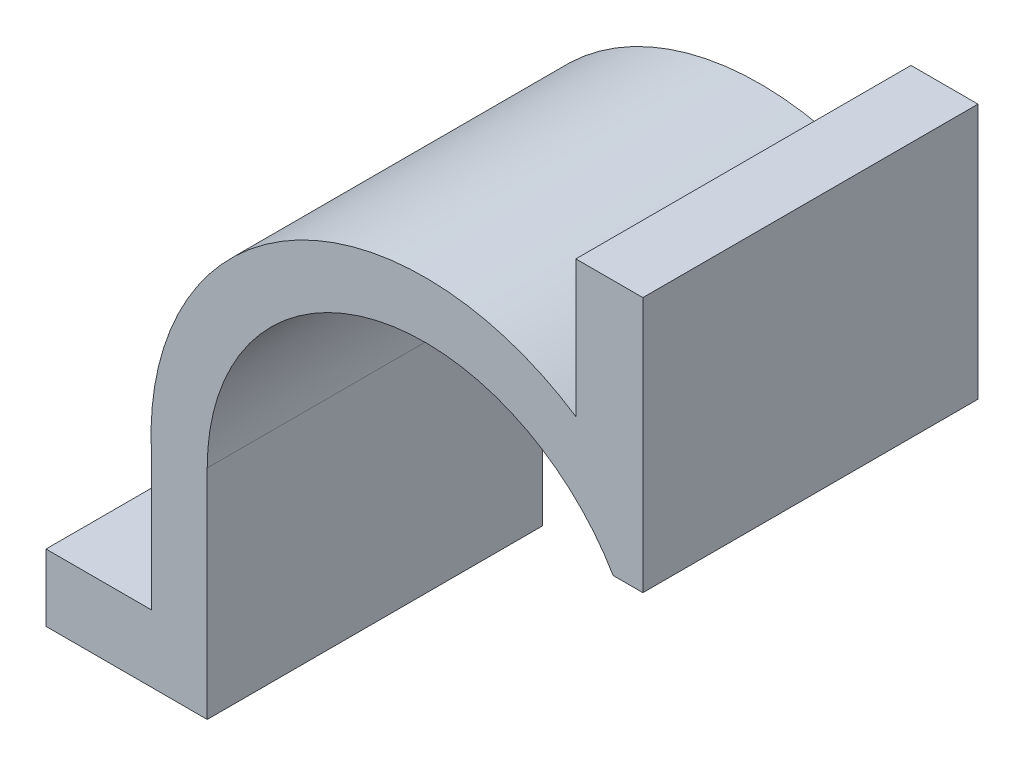
from build123d import *

# Parameters (mm, degrees)
BOSS_EXTRUDE1_DEPTH = 50


with BuildPart() as part:
    # Sketch2 → Boss-Extrude1 (new body)
    with BuildSketch(Plane.XY):
        with BuildLine():
            Line((-32.5, 0), (-32.5, -32.5))
            Line((-32.5, -32.5), (-56.553245639, -32.5))
            Line((-56.553245639, -32.5), (-56.553245639, -22.5))
            Line((-56.553245639, -22.5), (-40.8373789, -22.5))
            Line((-40.8373789, -22.5), (-40.8373789, -2.010804855))
            ThreePointArc((-40.8373789, -2.010804855), (-20.267475074, 35.510059219), (22.5, 34.139198169))
            Line((22.5, 34.139198169), (22.5, 54.513252466))
            Line((22.5, 54.513252466), (32.5, 54.513252466))
            Line((32.5, 54.513252466), (32.5, 16.381694729))
            Line((32.5, 16.381694729), (28.069379719, 16.381694729))
            ThreePointArc((28.069379719, 16.381694729), (-8.485138748, 31.372797459), (-32.5, 0))
        make_face()
    extrude(amount=-BOSS_EXTRUDE1_DEPTH)


solid = part.part
